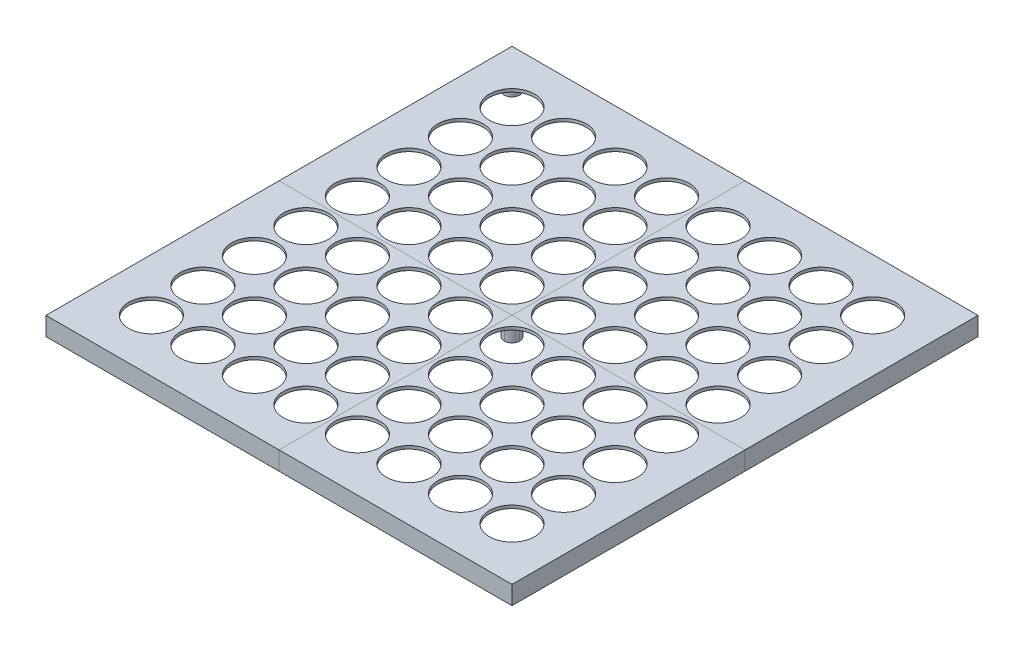
from build123d import *

# Parameters (mm, degrees)
SKETCH5_W                = 303
SKETCH5_H                = 303
BOSS_EXTRUDE4_DEPTH      = 2
SKETCH7_R                = 14.75
CUT_EXTRUDE5_DEPTH       = 429.511376745
LPATTERN7_COUNT          = 8
LPATTERN7_PITCH          = 33.5
LPATTERN7_COUNT_DIR2     = 8
LPATTERN7_PITCH_DIR2     = 33.5
SKETCH14_W               = 303
SKETCH14_H               = 303
BOSS_EXTRUDE7_DEPTH      = 10
SKETCH15_W               = 297
SKETCH15_H               = 297
CUT_EXTRUDE6_DEPTH       = 10
SKETCH16_R               = 5
BOSS_EXTRUDE8_DEPTH      = 10
SKETCH17_R               = 5
BOSS_EXTRUDE10_DEPTH     = 10
SKETCH18_R               = 5
BOSS_EXTRUDE11_DEPTH     = 10
SPLIT1_SURFACE_1_1_BACK  = 429.675
SPLIT1_SURFACE_1_1_DEPTH = 859.35
SPLIT1_SURFACE_1_2_BACK  = 429.675
SPLIT1_SURFACE_1_2_DEPTH = 859.35
SPLIT1_SURFACE_2_3_BACK  = 429.675
SPLIT1_SURFACE_2_3_DEPTH = 859.35
SPLIT1_SURFACE_2_4_BACK  = 429.675
SPLIT1_SURFACE_2_4_DEPTH = 859.35
SPLIT1_SURFACE_2_5_BACK  = 429.675
SPLIT1_SURFACE_2_5_DEPTH = 859.35
SPLIT1_SURFACE_2_6_BACK  = 429.675
SPLIT1_SURFACE_2_6_DEPTH = 859.35


with BuildPart() as part:
    # Sketch5 → Boss-Extrude4 (new body)
    with BuildSketch(Plane(origin=(0, 0, 0), x_dir=(1, 0, 0), z_dir=(0, 1, 0))):
        with Locations((151.5, 151.5)):
            Rectangle(SKETCH5_W, SKETCH5_H)
    extrude(amount=BOSS_EXTRUDE4_DEPTH)

    # Sketch7 → Cut-Extrude5 (cut, through all)
    with BuildSketch(Plane(origin=(0, 2, 0), x_dir=(1, 0, 0), z_dir=(0, 1, 0))):
        with Locations(Location((34.25, 34.25, 0), (0, 0, 270))):
            Circle(SKETCH7_R)
    cut_extrude5 = extrude(amount=-CUT_EXTRUDE5_DEPTH, mode=Mode.SUBTRACT)

    # LPattern7: Cut-Extrude5 8 × 8
    with Locations(*[(j * LPATTERN7_PITCH_DIR2, 0, -i * LPATTERN7_PITCH) for i in range(LPATTERN7_COUNT) for j in range(LPATTERN7_COUNT_DIR2) if (i, j) != (0, 0)]):
        add(cut_extrude5, mode=Mode.SUBTRACT)

    # Sketch14 → Boss-Extrude7 (add)
    with BuildSketch(Plane(origin=(0, 0, 0), x_dir=(1, 0, 0), z_dir=(0, 1, 0))):
        with Locations((151.5, 151.5)):
            Rectangle(SKETCH14_W, SKETCH14_H)
    extrude(amount=-BOSS_EXTRUDE7_DEPTH)

    # Sketch15 → Cut-Extrude6 (cut)
    with BuildSketch(Plane(origin=(0, 0, 0), x_dir=(1, 0, 0), z_dir=(0, 1, 0))):
        with Locations((151.5, 151.5)):
            Rectangle(SKETCH15_W, SKETCH15_H)
    extrude(amount=-CUT_EXTRUDE6_DEPTH, mode=Mode.SUBTRACT)

    # Sketch16 → Boss-Extrude8 (add)
    with BuildSketch(Plane(origin=(0, 0, 0), x_dir=(-1, 0, 0), z_dir=(0, -1, 0))):
        with Locations(Location((-151.5, 151.5, 0), (0, 0, 90))):
            Circle(SKETCH16_R)
    extrude(amount=BOSS_EXTRUDE8_DEPTH)

    # Sketch17 → Boss-Extrude10 (add)
    with BuildSketch(Plane(origin=(0, 0, 0), x_dir=(1, 0, 0), z_dir=(0, 1, 0))):
        with Locations(Location((13, 13, 0), (0, 0, 270))):
            Circle(SKETCH17_R)
    extrude(amount=-BOSS_EXTRUDE10_DEPTH)

    # Sketch18 → Boss-Extrude11 (add)
    with BuildSketch(Plane(origin=(0, 0, 0), x_dir=(1, 0, 0), z_dir=(0, 1, 0))):
        with Locations(Location((13, 290, 0), (0, 0, 270))):
            Circle(SKETCH18_R)
        with Locations(Location((290, 290, 0), (0, 0, 270))):
            Circle(SKETCH18_R)
        with Locations(Location((290, 13, 0), (0, 0, 270))):
            Circle(SKETCH18_R)
    extrude(amount=-BOSS_EXTRUDE11_DEPTH)


with BuildPart() as body_2:
    # Split1: the piece behind the surface
    add(part.part)
    # Split1 surface 1: a surface, the sketch's curves swept straight by 859.35 mm
    with BuildLine(Plane(origin=(0, 0, 0), x_dir=(1, 0, 0), z_dir=(0, 1, 0)).offset(-SPLIT1_SURFACE_1_1_BACK), mode=Mode.PRIVATE) as split1_surface_1_1_path:
        Line((151.5, 303), (151.5, 0))
    split1_surface_1_1 = Shell.extrude(split1_surface_1_1_path.wire(), (0 * SPLIT1_SURFACE_1_1_DEPTH, 1 * SPLIT1_SURFACE_1_1_DEPTH, 0 * SPLIT1_SURFACE_1_1_DEPTH))
    split(bisect_by=split1_surface_1_1, keep=Keep.BOTTOM)


with BuildPart() as part_1:
    add(part.part)

    # Split1: split by a surface, the side it looks to stays
    # Split1 surface 1: a surface, the sketch's curves swept straight by 859.35 mm
    with BuildLine(Plane(origin=(0, 0, 0), x_dir=(1, 0, 0), z_dir=(0, 1, 0)).offset(-SPLIT1_SURFACE_1_2_BACK), mode=Mode.PRIVATE) as split1_surface_1_2_path:
        Line((151.5, 303), (151.5, 0))
    split1_surface_1_2 = Shell.extrude(split1_surface_1_2_path.wire(), (0 * SPLIT1_SURFACE_1_2_DEPTH, 1 * SPLIT1_SURFACE_1_2_DEPTH, 0 * SPLIT1_SURFACE_1_2_DEPTH))
    split(bisect_by=split1_surface_1_2, keep=Keep.TOP)


with BuildPart() as body_3:
    # Split1 2: the piece behind the surface
    add(part_1.part)
    # Split1 surface 2: a surface, the sketch's curves swept straight by 859.35 mm
    with BuildLine(Plane(origin=(0, 0, 0), x_dir=(1, 0, 0), z_dir=(0, 1, 0)).offset(-SPLIT1_SURFACE_2_3_BACK), mode=Mode.PRIVATE) as split1_surface_2_3_path:
        Line((0, 151.5), (303, 151.5))
    split1_surface_2_3 = Shell.extrude(split1_surface_2_3_path.wire(), (0 * SPLIT1_SURFACE_2_3_DEPTH, 1 * SPLIT1_SURFACE_2_3_DEPTH, 0 * SPLIT1_SURFACE_2_3_DEPTH))
    split(bisect_by=split1_surface_2_3, keep=Keep.BOTTOM)


with BuildPart() as part_2:
    add(part_1.part)

    # Split1 2: split by a surface, the side it looks to stays
    # Split1 surface 2: a surface, the sketch's curves swept straight by 859.35 mm
    with BuildLine(Plane(origin=(0, 0, 0), x_dir=(1, 0, 0), z_dir=(0, 1, 0)).offset(-SPLIT1_SURFACE_2_4_BACK), mode=Mode.PRIVATE) as split1_surface_2_4_path:
        Line((0, 151.5), (303, 151.5))
    split1_surface_2_4 = Shell.extrude(split1_surface_2_4_path.wire(), (0 * SPLIT1_SURFACE_2_4_DEPTH, 1 * SPLIT1_SURFACE_2_4_DEPTH, 0 * SPLIT1_SURFACE_2_4_DEPTH))
    split(bisect_by=split1_surface_2_4, keep=Keep.TOP)


with BuildPart() as body_4:
    # Split1 2 body 2: the piece behind the surface
    add(body_2.part)
    # Split1 surface 2: a surface, the sketch's curves swept straight by 859.35 mm
    with BuildLine(Plane(origin=(0, 0, 0), x_dir=(1, 0, 0), z_dir=(0, 1, 0)).offset(-SPLIT1_SURFACE_2_5_BACK), mode=Mode.PRIVATE) as split1_surface_2_5_path:
        Line((0, 151.5), (303, 151.5))
    split1_surface_2_5 = Shell.extrude(split1_surface_2_5_path.wire(), (0 * SPLIT1_SURFACE_2_5_DEPTH, 1 * SPLIT1_SURFACE_2_5_DEPTH, 0 * SPLIT1_SURFACE_2_5_DEPTH))
    split(bisect_by=split1_surface_2_5, keep=Keep.BOTTOM)


with BuildPart() as body_2_1:
    add(body_2.part)

    # Split1 2 body 2: split by a surface, the side it looks to stays
    # Split1 surface 2: a surface, the sketch's curves swept straight by 859.35 mm
    with BuildLine(Plane(origin=(0, 0, 0), x_dir=(1, 0, 0), z_dir=(0, 1, 0)).offset(-SPLIT1_SURFACE_2_6_BACK), mode=Mode.PRIVATE) as split1_surface_2_6_path:
        Line((0, 151.5), (303, 151.5))
    split1_surface_2_6 = Shell.extrude(split1_surface_2_6_path.wire(), (0 * SPLIT1_SURFACE_2_6_DEPTH, 1 * SPLIT1_SURFACE_2_6_DEPTH, 0 * SPLIT1_SURFACE_2_6_DEPTH))
    split(bisect_by=split1_surface_2_6, keep=Keep.TOP)


solid = Compound([body_3.part, part_2.part, body_4.part, body_2_1.part])
